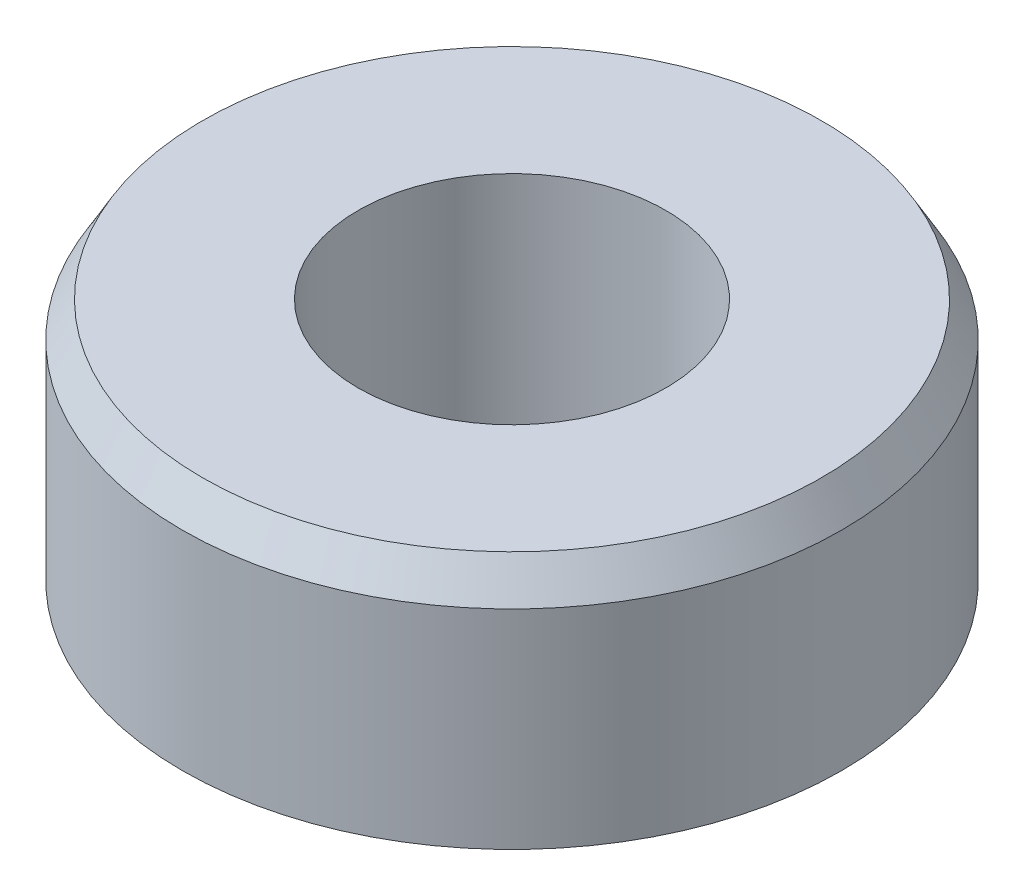
from build123d import *

# Parameters (mm, degrees)
SKETCH1_R             = 3.75
SKETCH1_R_2           = 1.75
BOSS_EXTRUDE1_DEPTH   = 3
CHAMFER1_SIZE         = 0.4
CHAMFER1_SIZE2        = 0.230940108
CHAMFER1_PART_2_SIZE  = 0.4
CHAMFER1_PART_2_SIZE2 = 0.230940108


with BuildPart() as part:
    # Sketch1 → Boss-Extrude1 (new body)
    with BuildSketch(Plane(origin=(0, 0, 0), x_dir=(1, 0, 0), z_dir=(0, 1, 0))):
        Circle(SKETCH1_R)
        Circle(SKETCH1_R_2, mode=Mode.SUBTRACT)
    extrude(amount=BOSS_EXTRUDE1_DEPTH)

    # Chamfer1
    chamfer1_edges = [part.edges().sort_by_distance(p)[0] for p in [
        (-3.75, 0, 0),
    ]]
    chamfer1_side = [part.faces().sort_by_distance(p)[0] for p in [
        (-3.643933983, 0, 0),
    ]]
    chamfer(chamfer1_edges, length=CHAMFER1_SIZE, length2=CHAMFER1_SIZE2, reference=chamfer1_side[0])

    # Chamfer1 part 2
    chamfer1_part_2_edges = [part.edges().sort_by_distance(p)[0] for p in [
        (-3.75, 3, 0),
    ]]
    chamfer1_part_2_side = [part.faces().sort_by_distance(p)[0] for p in [
        (-3.75, 1.5, 0),
    ]]
    chamfer(chamfer1_part_2_edges, length=CHAMFER1_PART_2_SIZE, length2=CHAMFER1_PART_2_SIZE2, reference=chamfer1_part_2_side[0])


solid = part.part
